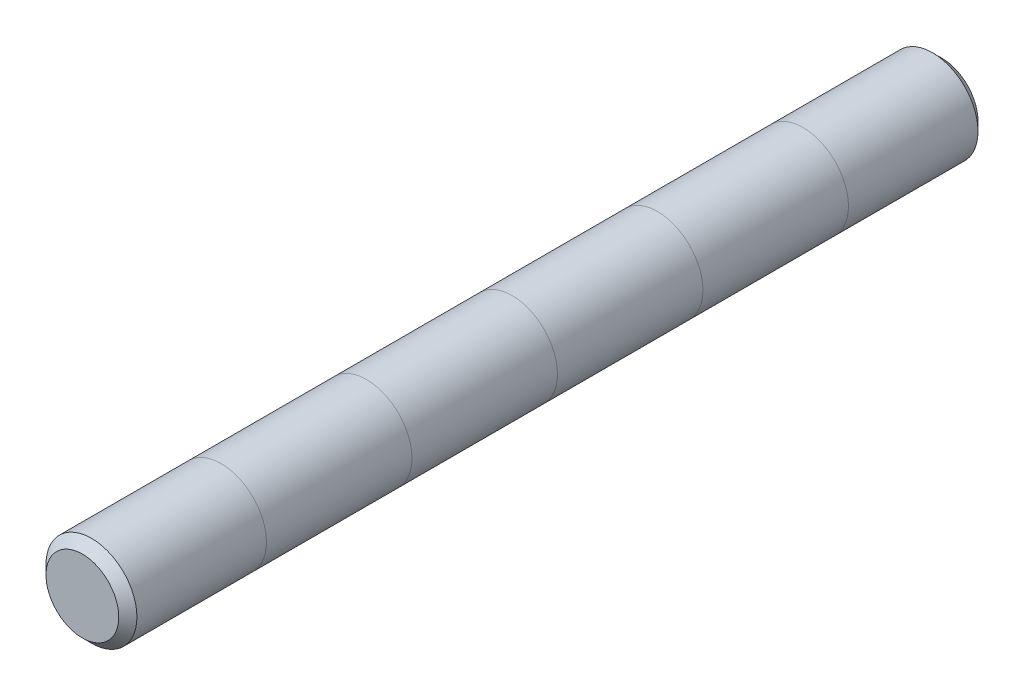
from build123d import *

# Parameters (mm, degrees)
SKETCH3_R           = 7.9375
BOSS_EXTRUDE1_DEPTH = 75
CHAMFER1_SIZE       = 1.5875


with BuildPart() as part:
    # Sketch3 → Boss-Extrude1 (new body, symmetric)
    with BuildSketch(Plane.XY):
        Circle(SKETCH3_R)
    extrude(amount=BOSS_EXTRUDE1_DEPTH, both=True)

    # Chamfer1
    chamfer1_edges = [part.edges().sort_by_distance(p)[0] for p in [
        (-7.9375, 0, -75),
        (-7.9375, 0, 75),
    ]]
    chamfer(chamfer1_edges, length=CHAMFER1_SIZE)


solid = part.part
